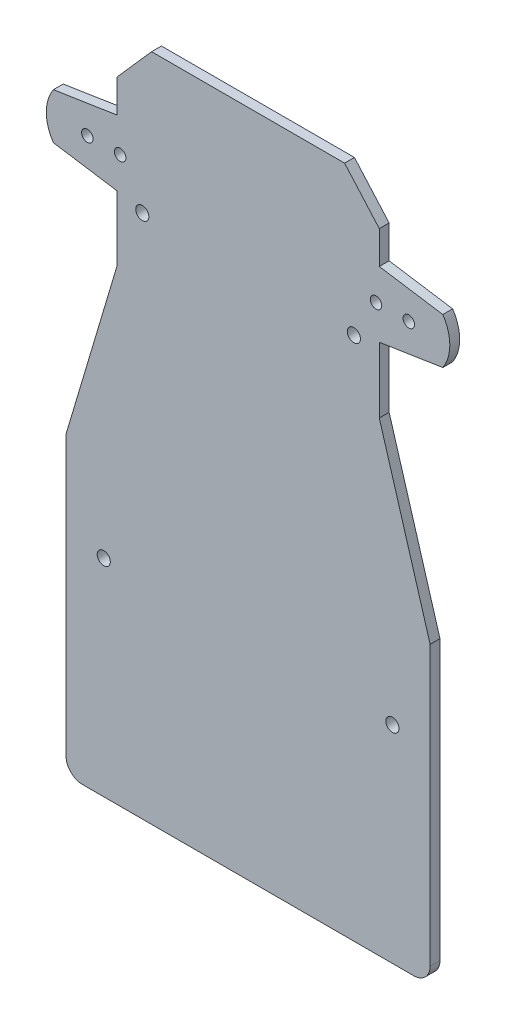
from build123d import *

# Parameters (mm, degrees)
SKETCH_1_R      = 1.75
EXTRUDE_1_DEPTH = 3
FILLET_1_R      = 5
MM_1_D          = 4


with BuildPart() as part:
    # 草图1 → 凸台-拉伸1 (new body)
    with BuildSketch(Plane.XY):
        with BuildLine():
            Line((-29.416994756, 204), (29.416994756, 204))
            Line((29.416994756, 204), (40, 192))
            Line((40, 192), (40, 182))
            Line((40, 182), (59.356157589, 179))
            ThreePointArc((59.356157589, 179), (61.5, 172), (59.356157589, 165))
            Line((59.356157589, 165), (40, 162))
            Line((40, 162), (40, 142))
            Line((40, 142), (55.5, 90))
            Line((55.5, 90), (55.5, 0))
            Line((55.5, 0), (-55.5, 0))
            Line((-55.5, 0), (-55.5, 90))
            Line((-55.5, 90), (-40, 142))
            Line((-40, 142), (-40, 162))
            Line((-40, 162), (-59.356157589, 165))
            ThreePointArc((-59.356157589, 165), (-61.5, 172), (-59.356157589, 179))
            Line((-59.356157589, 179), (-40, 182))
            Line((-40, 182), (-40, 192))
            Line((-40, 192), (-29.416994756, 204))
        make_face()
        with Locations((-49, 172)):
            Circle(SKETCH_1_R, mode=Mode.SUBTRACT)
        with Locations((49, 172)):
            Circle(SKETCH_1_R, mode=Mode.SUBTRACT)
        with Locations((39, 172)):
            Circle(SKETCH_1_R, mode=Mode.SUBTRACT)
        with Locations((-39, 172)):
            Circle(SKETCH_1_R, mode=Mode.SUBTRACT)
    extrude(amount=EXTRUDE_1_DEPTH)

    # 圆角1
    fillet_1_edges = [part.edges().sort_by_distance(p)[0] for p in [
        (55.5, 0, 1.5),
        (-55.5, 0, 1.5),
    ]]
    fillet(fillet_1_edges, radius=FILLET_1_R)

    # 大小mm 暗销孔1 (through all)
    with Locations(Plane(origin=(0, 0, 0), x_dir=(-1, 0, 0), z_dir=(0, 0, -1))):
        with Locations((-32.25, 160), (32.25, 160), (44, 63), (-44, 63)):
            Hole(MM_1_D / 2)


solid = part.part
